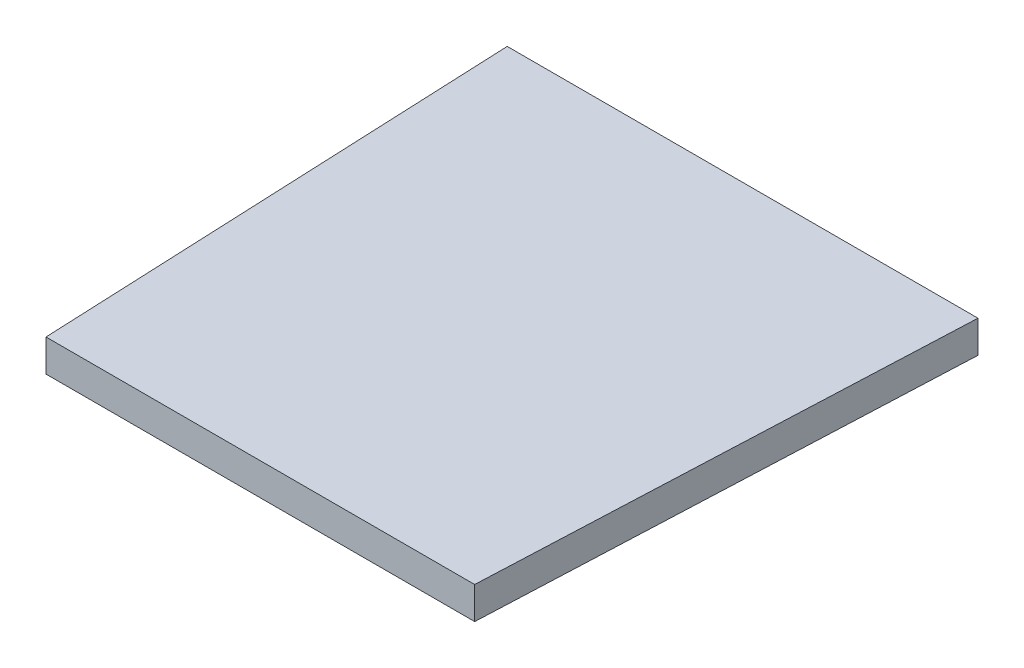
from build123d import *

# Parameters (mm, degrees)
BOSS_EXTRUDE1_DEPTH = 3


with BuildPart() as part:
    # Sketch1 → Boss-Extrude1 (new body)
    with BuildSketch(Plane(origin=(0, 0, 0), x_dir=(1, 0, 0), z_dir=(0, 1, 0))):
        Polygon((-21.964742431, 100), (-20, 55), (0, 55), (0, 100), align=None)
    boss_extrude1 = extrude(amount=BOSS_EXTRUDE1_DEPTH)

    # Mirror2: Boss-Extrude1 across plane
    add(boss_extrude1.mirror(Plane(origin=(0, 0, 0), x_dir=(0, 0, 1), z_dir=(1, 0, 0))))


solid = part.part
